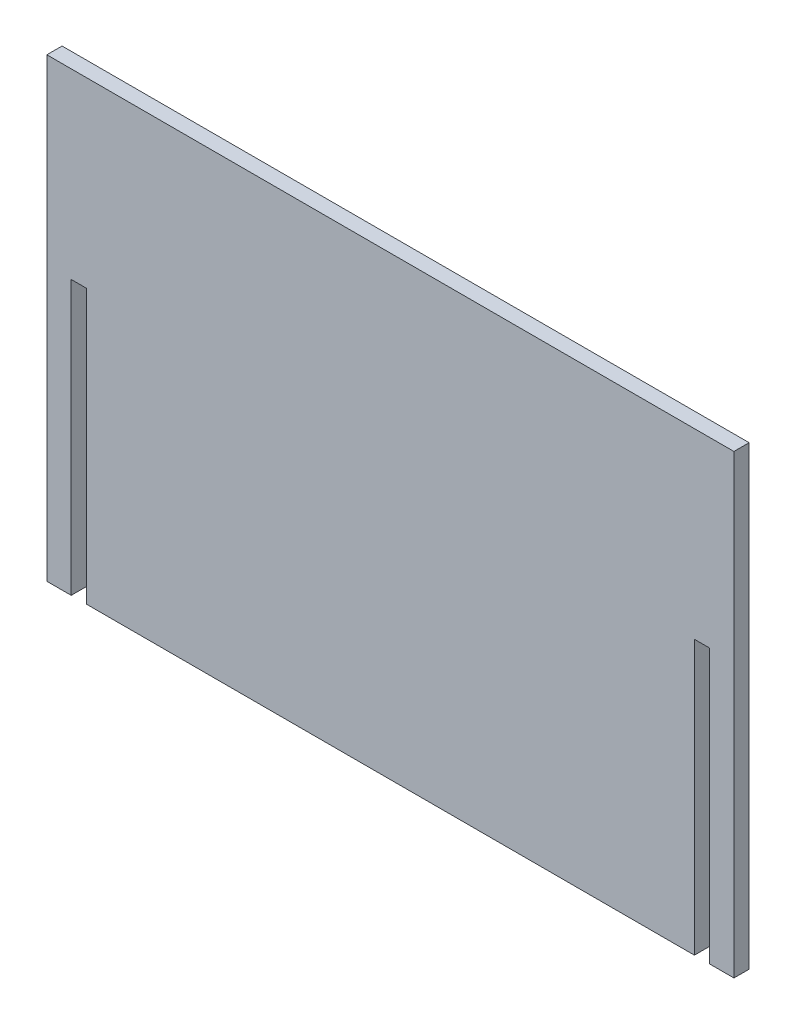
from build123d import *

# Parameters (mm, degrees)
BOSS_EXTRU_1_DEPTH = 5


with BuildPart() as part:
    # Esquisse1 → Boss.-Extru.1 (new body)
    with BuildSketch(Plane.XY):
        Polygon((0, 0), (0, 150), (226, 150), (226, 0), (218, 0), (218, 90), (213, 90), (213, 0), (13, 0), (13, 90), (8, 90), (8, 0), align=None)
    extrude(amount=BOSS_EXTRU_1_DEPTH)


solid = part.part
